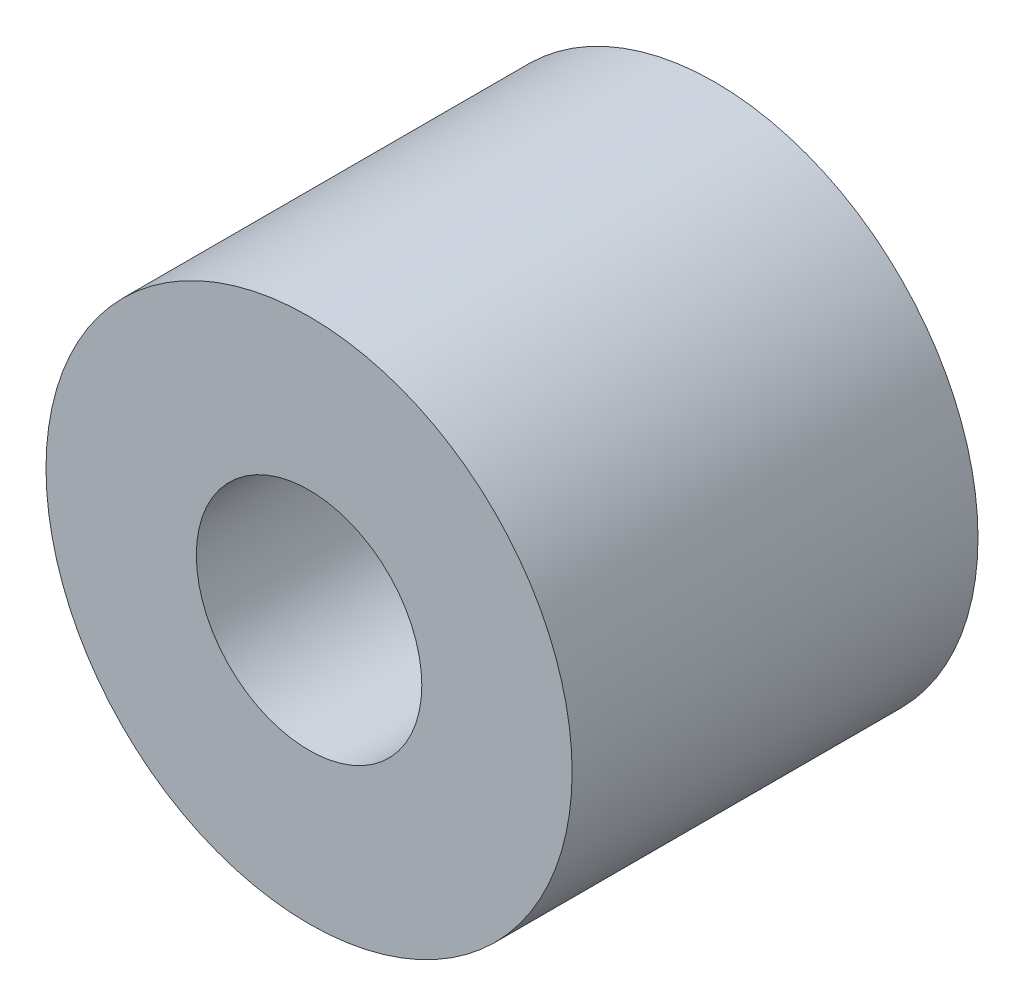
from build123d import *

# Parameters (mm, degrees)
SKETCH1_R           = 3.5
SKETCH1_R_2         = 1.5
BOSS_EXTRUDE1_DEPTH = 5.4


with BuildPart() as part:
    # Sketch1 → Boss-Extrude1 (new body)
    with BuildSketch(Plane.XY):
        Circle(SKETCH1_R)
        Circle(SKETCH1_R_2, mode=Mode.SUBTRACT)
    extrude(amount=BOSS_EXTRUDE1_DEPTH)


solid = part.part
